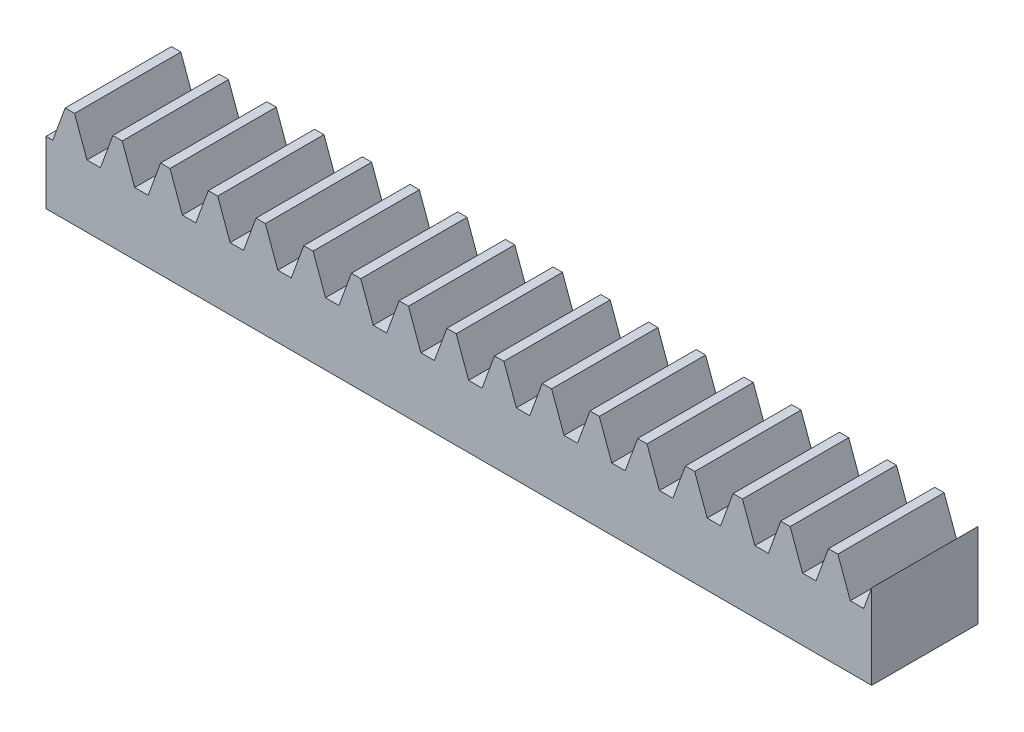
from build123d import *

# Parameters (mm, degrees)
BLANKSKE_W        = 21.75
BLANKSKE_H        = 2.55
BLANK_DEPTH       = 2.8
TOOTHCUTSIM_DEPTH = 23.077250735
TEETHCUTS_COUNT   = 18
TEETHCUTS_PITCH   = 1.25663706


with BuildPart() as part:
    # BlankSke → Blank (new body)
    with BuildSketch(Plane.XY):
        with Locations((10.875, 1.275)):
            Rectangle(BLANKSKE_W, BLANKSKE_H)
    extrude(amount=-BLANK_DEPTH)

    # TooCutSkeSim → ToothCutSim (cut, through all)
    with BuildSketch(Plane.XY):
        Polygon((0.177174148, 1.65), (-0.177174148, 1.65), (-0.513992203, 2.5754), (0.513992203, 2.5754), align=None)
    toothcutsim = extrude(amount=-TOOTHCUTSIM_DEPTH, mode=Mode.SUBTRACT)

    # TeethCuts: ToothCutSim ×18
    with Locations(*[(i * TEETHCUTS_PITCH, 0, 0) for i in range(1, TEETHCUTS_COUNT)]):
        add(toothcutsim, mode=Mode.SUBTRACT)


solid = part.part
